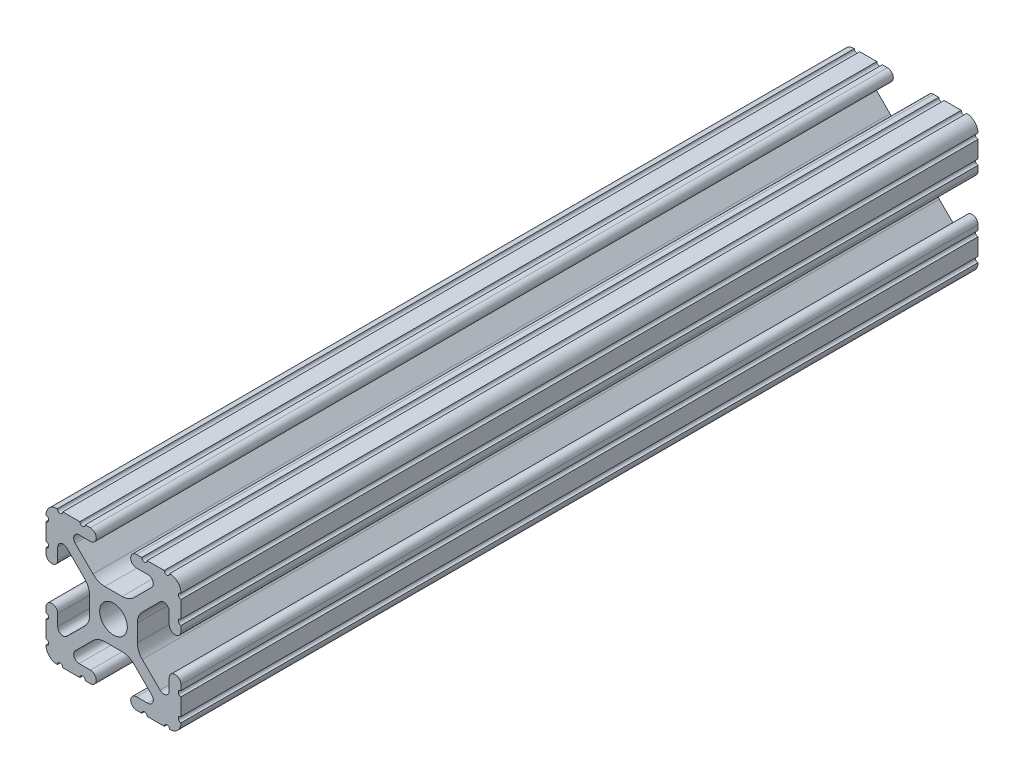
from build123d import *

# Parameters (mm, degrees)
SKETCH1_R           = 2.6035
BOSS_EXTRUDE1_DEPTH = 150


with BuildPart() as part:
    # Sketch1 → Boss-Extrude1 (new body)
    with BuildSketch(Plane(origin=(0, 0, -381), x_dir=(-1, 0, 0), z_dir=(0, 0, -1))):
        with BuildLine():
            Line((12.7, -9.5504), (12.7, -6.3330836))
            ThreePointArc((12.7, -6.3330836), (12.192, -5.8250836), (12.7, -5.3170836))
            Line((12.7, -5.3170836), (12.7, -4.3434))
            ThreePointArc((12.7, -4.3434), (11.5951, -3.2385), (10.4902, -4.3434))
            Line((10.4902, -4.3434), (10.4902, -6.474794456))
            ThreePointArc((10.4902, -6.474794456), (9.863006367, -7.413456061), (8.75577951, -7.193214945))
            Line((8.75577951, -7.193214945), (5.42573597, -3.863171405))
            ThreePointArc((5.42573597, -3.863171405), (4.737482484, -2.833127272), (4.4958, -1.618107374))
            Line((4.4958, -1.618107374), (4.4958, 1.618107374))
            ThreePointArc((4.4958, 1.618107374), (4.737482484, 2.833127272), (5.42573597, 3.863171405))
            Line((5.42573597, 3.863171405), (8.75577951, 7.193214945))
            ThreePointArc((8.75577951, 7.193214945), (9.863006367, 7.413456061), (10.4902, 6.474794456))
            Line((10.4902, 6.474794456), (10.4902, 4.343399971))
            ThreePointArc((10.4902, 4.343399971), (11.5951, 3.238499971), (12.7, 4.343399971))
            Line((12.7, 4.343399971), (12.7, 5.3170836))
            ThreePointArc((12.7, 5.3170836), (12.192, 5.8250836), (12.7, 6.3330836))
            Line((12.7, 6.3330836), (12.7, 9.5504))
            ThreePointArc((12.7, 9.5504), (12.192000006, 10.058323491), (12.699846982, 10.566399977))
            ThreePointArc((12.699846982, 10.566399977), (12.082522516, 12.082522516), (10.566399977, 12.699846982))
            ThreePointArc((10.566399977, 12.699846982), (10.058323491, 12.192000006), (9.5504, 12.7))
            Line((9.5504, 12.7), (6.3330836, 12.7))
            ThreePointArc((6.3330836, 12.7), (5.8250836, 12.192), (5.3170836, 12.7))
            Line((5.3170836, 12.7), (4.3434, 12.7))
            ThreePointArc((4.3434, 12.7), (3.2385, 11.5951), (4.3434, 10.4902))
            Line((4.3434, 10.4902), (6.474794456, 10.4902))
            ThreePointArc((6.474794456, 10.4902), (7.413456061, 9.863006367), (7.193214945, 8.75577951))
            Line((7.193214945, 8.75577951), (3.863171405, 5.42573597))
            ThreePointArc((3.863171405, 5.42573597), (2.833127272, 4.737482484), (1.618107374, 4.4958))
            Line((1.618107374, 4.4958), (-1.618107374, 4.4958))
            ThreePointArc((-1.618107374, 4.4958), (-2.833127272, 4.737482484), (-3.863171405, 5.42573597))
            Line((-3.863171405, 5.42573597), (-7.193214945, 8.75577951))
            ThreePointArc((-7.193214945, 8.75577951), (-7.413456061, 9.863006367), (-6.474794456, 10.4902))
            Line((-6.474794456, 10.4902), (-4.343399971, 10.4902))
            ThreePointArc((-4.343399971, 10.4902), (-3.238499971, 11.5951), (-4.343399971, 12.7))
            Line((-4.343399971, 12.7), (-5.3170836, 12.7))
            ThreePointArc((-5.3170836, 12.7), (-5.8250836, 12.192), (-6.3330836, 12.7))
            Line((-6.3330836, 12.7), (-9.5504, 12.7))
            ThreePointArc((-9.5504, 12.7), (-10.058323491, 12.192000006), (-10.566399977, 12.699846982))
            ThreePointArc((-10.566399977, 12.699846982), (-12.082522516, 12.082522516), (-12.699846982, 10.566399977))
            ThreePointArc((-12.699846982, 10.566399977), (-12.192000006, 10.058323491), (-12.7, 9.5504))
            Line((-12.7, 9.5504), (-12.7, 6.3330836))
            ThreePointArc((-12.7, 6.3330836), (-12.192, 5.8250836), (-12.7, 5.3170836))
            Line((-12.7, 5.3170836), (-12.7, 4.3434))
            ThreePointArc((-12.7, 4.3434), (-11.5951, 3.2385), (-10.4902, 4.3434))
            Line((-10.4902, 4.3434), (-10.4902, 6.474794456))
            ThreePointArc((-10.4902, 6.474794456), (-9.863006367, 7.413456061), (-8.75577951, 7.193214945))
            Line((-8.75577951, 7.193214945), (-5.42573597, 3.863171405))
            ThreePointArc((-5.42573597, 3.863171405), (-4.737482484, 2.833127272), (-4.4958, 1.618107374))
            Line((-4.4958, 1.618107374), (-4.4958, -1.618107374))
            ThreePointArc((-4.4958, -1.618107374), (-4.737482484, -2.833127272), (-5.42573597, -3.863171405))
            Line((-5.42573597, -3.863171405), (-8.75577951, -7.193214945))
            ThreePointArc((-8.75577951, -7.193214945), (-9.863006367, -7.413456061), (-10.4902, -6.474794456))
            Line((-10.4902, -6.474794456), (-10.4902, -4.343399971))
            ThreePointArc((-10.4902, -4.343399971), (-11.5951, -3.238499971), (-12.7, -4.343399971))
            Line((-12.7, -4.343399971), (-12.7, -5.3170836))
            ThreePointArc((-12.7, -5.3170836), (-12.192, -5.8250836), (-12.7, -6.3330836))
            Line((-12.7, -6.3330836), (-12.7, -9.5504))
            ThreePointArc((-12.7, -9.5504), (-12.192000006, -10.058323491), (-12.699846982, -10.566399977))
            ThreePointArc((-12.699846982, -10.566399977), (-12.082522516, -12.082522516), (-10.566399977, -12.699846982))
            ThreePointArc((-10.566399977, -12.699846982), (-10.058323491, -12.192000006), (-9.5504, -12.7))
            Line((-9.5504, -12.7), (-6.3330836, -12.7))
            ThreePointArc((-6.3330836, -12.7), (-5.8250836, -12.192), (-5.3170836, -12.7))
            Line((-5.3170836, -12.7), (-4.3434, -12.7))
            ThreePointArc((-4.3434, -12.7), (-3.2385, -11.5951), (-4.3434, -10.4902))
            Line((-4.3434, -10.4902), (-6.474794456, -10.4902))
            ThreePointArc((-6.474794456, -10.4902), (-7.413456061, -9.863006367), (-7.193214945, -8.75577951))
            Line((-7.193214945, -8.75577951), (-3.863171405, -5.42573597))
            ThreePointArc((-3.863171405, -5.42573597), (-2.833127272, -4.737482484), (-1.618107374, -4.4958))
            Line((-1.618107374, -4.4958), (1.618107374, -4.4958))
            ThreePointArc((1.618107374, -4.4958), (2.833127272, -4.737482484), (3.863171405, -5.42573597))
            Line((3.863171405, -5.42573597), (7.193214945, -8.75577951))
            ThreePointArc((7.193214945, -8.75577951), (7.413456061, -9.863006367), (6.474794456, -10.4902))
            Line((6.474794456, -10.4902), (4.343399971, -10.4902))
            ThreePointArc((4.343399971, -10.4902), (3.238499971, -11.5951), (4.343399971, -12.7))
            Line((4.343399971, -12.7), (5.3170836, -12.7))
            ThreePointArc((5.3170836, -12.7), (5.8250836, -12.192), (6.3330836, -12.7))
            Line((6.3330836, -12.7), (9.5504, -12.7))
            ThreePointArc((9.5504, -12.7), (10.058323491, -12.192000006), (10.566399977, -12.699846982))
            ThreePointArc((10.566399977, -12.699846982), (12.082522516, -12.082522516), (12.699846982, -10.566399977))
            ThreePointArc((12.699846982, -10.566399977), (12.192000006, -10.058323491), (12.7, -9.5504))
        make_face()
        Circle(SKETCH1_R, mode=Mode.SUBTRACT)
    extrude(amount=-BOSS_EXTRUDE1_DEPTH)


solid = part.part
